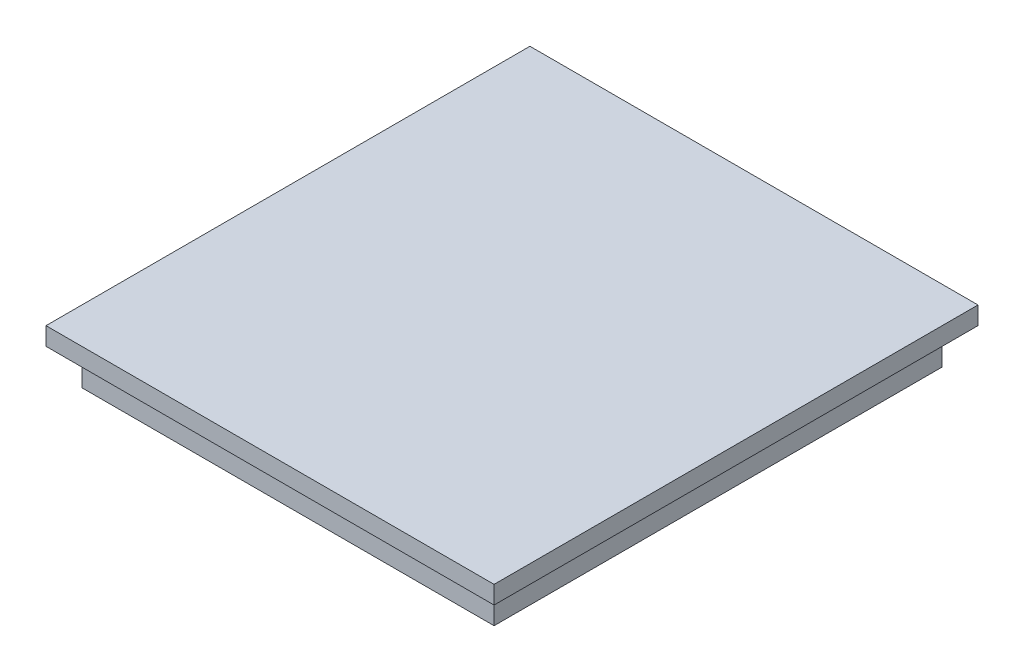
from build123d import *

# Parameters (mm, degrees)
SKETCH1_W           = 115
SKETCH1_H           = 125
BOSS_EXTRUDE1_DEPTH = 10
SKETCH2_W           = 125
SKETCH2_H           = 135
BOSS_EXTRUDE2_DEPTH = 5


with BuildPart() as part:
    # Sketch1 → Boss-Extrude1 (new body)
    with BuildSketch(Plane(origin=(0, 0, 0), x_dir=(1, 0, 0), z_dir=(0, 1, 0))):
        Rectangle(SKETCH1_W, SKETCH1_H)
    extrude(amount=BOSS_EXTRUDE1_DEPTH)

    # Sketch2 → Boss-Extrude2 (add)
    with BuildSketch(Plane(origin=(0, 10, 0), x_dir=(1, 0, 0), z_dir=(0, 1, 0))):
        Rectangle(SKETCH2_W, SKETCH2_H)
    extrude(amount=BOSS_EXTRUDE2_DEPTH)


solid = part.part
